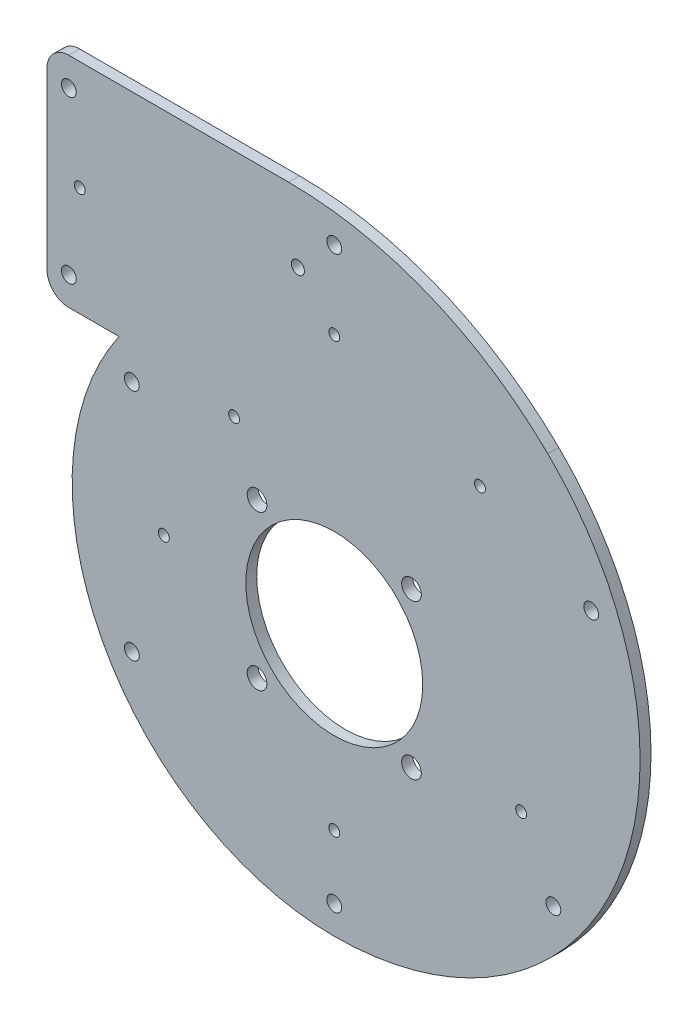
from build123d import *

# Parameters (mm, degrees)
BOSS_EXTRU_1_DEPTH           = 5
ESQUISSE11_R                 = 4.5
ENL_V_MAT_EXTRU_7_DEPTH      = 13
ENL_V_MAT_EXTRU_5_DEPTH      = 0.2
ESQUISSE2_R                  = 40.5
ENL_V_MAT_EXTRU_1_DEPTH      = 10
ESQUISSE3_R                  = 3
ENL_V_MAT_EXTRU_2_DEPTH      = 6
ESQUISSE10_R                 = 3.4
ENL_V_MAT_EXTRU_6_DEPTH      = 13
R_P_TITION_CIRCULAIRE1_COUNT = 4
BOSS_EXTRU_3_DEPTH           = 0.2
ESQUISSE26_W                 = 15
ESQUISSE26_H                 = 100
ENL_V_MAT_EXTRU_14_DEPTH     = 10
CONG_2_R                     = 10
ESQUISSE27_R                 = 2.5
ENL_V_MAT_EXTRU_15_DEPTH     = 10


with BuildPart() as part:
    # Esquisse1 → Boss.-Extru.1 (new body)
    with BuildSketch(Plane.XY):
        with BuildLine():
            Line((-98.507460241, 68.529411765), (-146.503153147, 68.529411765))
            Line((-146.503153147, 68.529411765), (-146.503153147, 168.529411765))
            Line((-146.503153147, 168.529411765), (-20.952657131, 168.529411765))
            ThreePointArc((-20.952657131, 168.529411765), (43.143624613, 155.983108662), (97.779066609, 120.196078431))
            ThreePointArc((97.779066609, 120.196078431), (129.667750386, -32.7851732), (0, -120))
            ThreePointArc((0, -120), (-84.852813742, -84.852813742), (-120, 0))
            ThreePointArc((-120, 0), (-114.500862942, 35.910338143), (-98.507460241, 68.529411765))
        make_face()
    extrude(amount=BOSS_EXTRU_1_DEPTH)

    # Esquisse11 → Enlèv. mat.-Extru.7 (cut)
    with BuildSketch(Plane.XY.offset(5)):
        with Locations((35.355339059, 35.355339059)):
            Circle(ESQUISSE11_R)
    enl_v_mat_extru_7 = extrude(amount=-ENL_V_MAT_EXTRU_7_DEPTH, mode=Mode.SUBTRACT)

    # Esquisse8 → Enlèv. mat.-Extru.5 (cut)
    with BuildSketch(Plane.XY.offset(5)):
        with BuildLine():
            Line((-148.503153147, 150.529411765), (-20.952657131, 150.529411765))
            ThreePointArc((-20.952657131, 150.529411765), (36.356959487, 139.311540755), (85.207472331, 107.31372549))
            ThreePointArc((85.207472331, 107.31372549), (112.996182479, -25.998508075), (0, -102))
            ThreePointArc((0, -102), (-98.056106388, -28.08914381), (-54.006119095, 86.529411765))
            Line((-54.006119095, 86.529411765), (-148.503153147, 86.529411765))
            Line((-148.503153147, 86.529411765), (-148.503153147, 150.529411765))
        make_face()
        with BuildLine():
            Line((-46.503153147, 88.529411765), (-146.503153147, 88.529411765))
            Line((-146.503153147, 88.529411765), (-146.503153147, 148.529411765))
            Line((-146.503153147, 148.529411765), (-20.952657131, 148.529411765))
            ThreePointArc((-20.952657131, 148.529411765), (35.602885584, 137.459144321), (83.810628522, 105.882352941))
            ThreePointArc((83.810628522, 105.882352941), (111.143786045, -25.244434172), (0, -100))
            ThreePointArc((0, -100), (-97.090012814, -23.948474101), (-46.503153147, 88.529411765))
        make_face(mode=Mode.SUBTRACT)
    extrude(amount=-ENL_V_MAT_EXTRU_5_DEPTH, mode=Mode.SUBTRACT)

    # Esquisse2 → Enlèv. mat.-Extru.1 (cut)
    with BuildSketch(Plane.XY.offset(5)):
        Circle(ESQUISSE2_R)
    extrude(amount=-ENL_V_MAT_EXTRU_1_DEPTH, mode=Mode.SUBTRACT)

    # Esquisse3 → Enlèv. mat.-Extru.2 (cut, through all)
    with BuildSketch(Plane(origin=(0, 0, 0), x_dir=(-1, 0, 0), z_dir=(0, 0, -1))):
        with Locations((16.656037964, 136.868437771)):
            Circle(ESQUISSE3_R)
    extrude(amount=-ENL_V_MAT_EXTRU_2_DEPTH, mode=Mode.SUBTRACT)

    # Esquisse10 → Enlèv. mat.-Extru.6 (cut)
    with BuildSketch(Plane.XY.offset(5)):
        with Locations((-121.503153147, 155.529411765)):
            Circle(ESQUISSE10_R)
        with Locations((117.617814583, 67.906676911)):
            Circle(ESQUISSE10_R)
        with Locations((100.297306508, -57.906676911)):
            Circle(ESQUISSE10_R)
        with Locations((0, -107)):
            Circle(ESQUISSE10_R)
        with Locations((-92.664718205, -53.5)):
            Circle(ESQUISSE10_R)
        with Locations((-92.664718205, 53.5)):
            Circle(ESQUISSE10_R)
        with Locations((-121.503153147, 81.529411765)):
            Circle(ESQUISSE10_R)
        with Locations((0, 154.124997046)):
            Circle(ESQUISSE10_R)
    extrude(amount=-ENL_V_MAT_EXTRU_6_DEPTH, mode=Mode.SUBTRACT)

    # Répétition circulaire1: Enlèv. mat.-Extru.7 ×4 about axis
    r_p_tition_circulaire1_axis = Axis((0, 0, 0), (0, 0, 1))
    for i in range(1, R_P_TITION_CIRCULAIRE1_COUNT):
        add(enl_v_mat_extru_7.rotate(r_p_tition_circulaire1_axis, i * 360 / R_P_TITION_CIRCULAIRE1_COUNT), mode=Mode.SUBTRACT)

    # Esquisse24 → Boss.-Extru.3 (add)
    with BuildSketch(Plane.XY.offset(5)):
        with BuildLine():
            Line((-146.503153147, 150.529411765), (-146.503153147, 148.529411765))
            Line((-146.503153147, 148.529411765), (-20.952657131, 148.529411765))
            ThreePointArc((-20.952657131, 148.529411765), (35.602885584, 137.459144321), (83.810628522, 105.882352941))
            ThreePointArc((83.810628522, 105.882352941), (111.143786045, -25.244434172), (0, -100))
            ThreePointArc((0, -100), (-97.090012814, -23.948474101), (-46.503153147, 88.529411765))
            Line((-46.503153147, 88.529411765), (-146.503153147, 88.529411765))
            Line((-146.503153147, 88.529411765), (-146.503153147, 86.529411765))
            Line((-146.503153147, 86.529411765), (-54.006119095, 86.529411765))
            ThreePointArc((-54.006119095, 86.529411765), (-98.056106388, -28.08914381), (0, -102))
            ThreePointArc((0, -102), (112.996182479, -25.998508075), (85.207472331, 107.31372549))
            ThreePointArc((85.207472331, 107.31372549), (36.356959487, 139.311540755), (-20.952657131, 150.529411765))
            Line((-20.952657131, 150.529411765), (-146.503153147, 150.529411765))
        make_face()
    extrude(amount=-BOSS_EXTRU_3_DEPTH)

    # Esquisse26 → Enlèv. mat.-Extru.14 (cut)
    with BuildSketch(Plane.XY.offset(5)):
        with Locations((-139.003153147, 118.529411765)):
            Rectangle(ESQUISSE26_W, ESQUISSE26_H)
    extrude(amount=-ENL_V_MAT_EXTRU_14_DEPTH, mode=Mode.SUBTRACT)

    # Congé2
    cong_2_edges = [part.edges().sort_by_distance(p)[0] for p in [
        (-131.503153147, 168.529411765, 2.5),
        (-131.503153147, 68.529411765, 2.5),
    ]]
    fillet(cong_2_edges, radius=CONG_2_R)

    # Esquisse27 → Enlèv. mat.-Extru.15 (cut)
    with BuildSketch(Plane.XY.offset(5)):
        with Locations((-116.503153147, 118.529411765)):
            Circle(ESQUISSE27_R)
        with Locations((0, 118.529411765)):
            Circle(ESQUISSE27_R)
        with Locations((66.701706035, 91.807022251)):
            Circle(ESQUISSE27_R)
        with Locations((85.55324371, -27.797933958)):
            Circle(ESQUISSE27_R)
        with Locations((0, -78)):
            Circle(ESQUISSE27_R)
        with Locations((-45.847249679, 63.103325561)):
            Circle(ESQUISSE27_R)
        with Locations((-78, 0)):
            Circle(ESQUISSE27_R)
    extrude(amount=-ENL_V_MAT_EXTRU_15_DEPTH, mode=Mode.SUBTRACT)


solid = part.part
